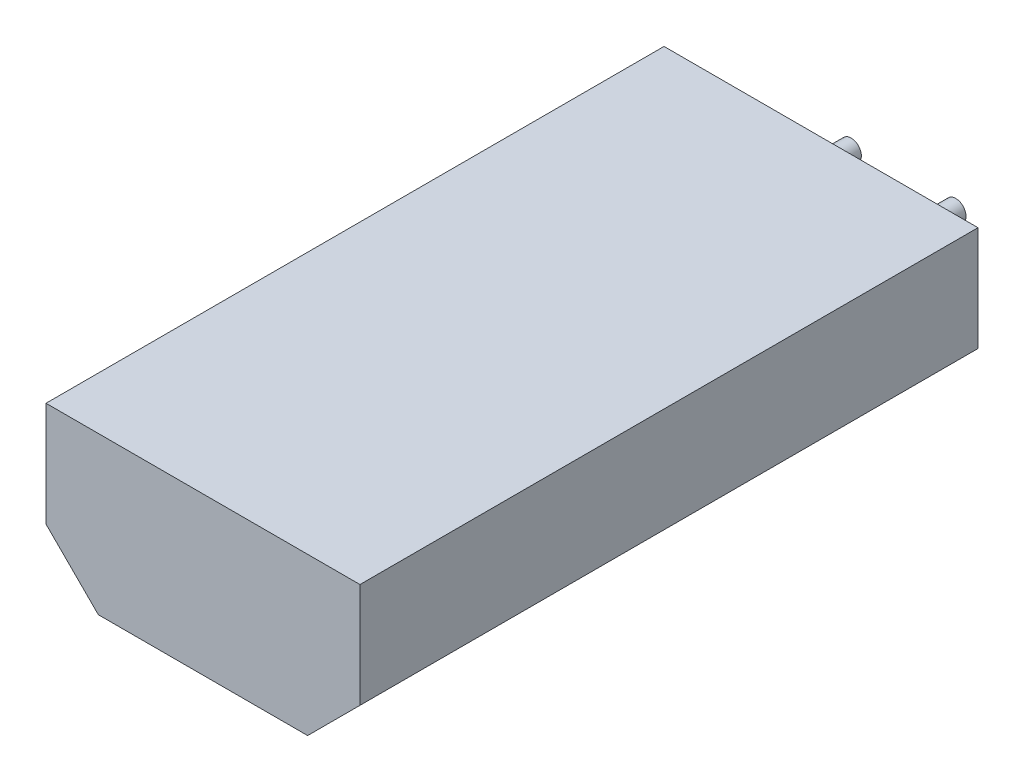
from build123d import *

# Parameters (mm, degrees)
COMPONENT_OUTLINE_DEPTH = 15
SKETCH2_R               = 0.25
EXTRUDE_1_DEPTH         = 2
SKETCH3_R               = 0.25
EXTRUDE_2_DEPTH         = 2


with BuildPart() as part:
    # Sketch1 → Component_Outline (new body)
    with BuildSketch(Plane.XY):
        Polygon((-2.54, 1.905), (-2.54, -0.635), (-1.27, -1.905), (3.81, -1.905), (5.08, -0.635), (5.08, 1.905), align=None)
    extrude(amount=COMPONENT_OUTLINE_DEPTH)


with BuildPart() as body_2:
    # Sketch2 → Extrude 1 (new body)
    with BuildSketch(Plane.XY):
        Circle(SKETCH2_R)
    extrude(amount=-EXTRUDE_1_DEPTH)


with BuildPart() as body_3:
    # Sketch3 → Extrude 2 (new body)
    with BuildSketch(Plane.XY):
        with Locations((2.54, 0)):
            Circle(SKETCH3_R)
    extrude(amount=-EXTRUDE_2_DEPTH)


solid = Compound([part.part, body_2.part, body_3.part])
